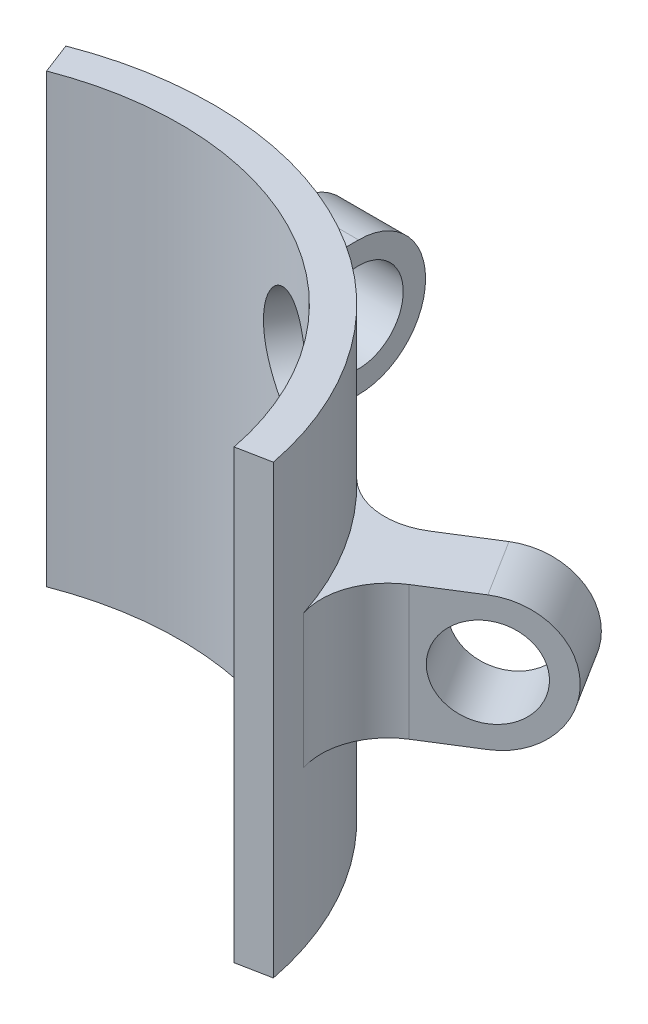
from build123d import *
from build123d.topology import SkipClean

# Parameters (mm, degrees)
SKETCH2_R               = 15.5
SKETCH2_R_2             = 14
BOSS_EXTRUDE1_DEPTH     = 20
SKETCH3_OUTSIDE_W       = 42.638
SKETCH3_OUTSIDE_H       = 42.638
CUT_EXTRUDE1_DEPTH      = 30.67322025
SKETCH6_R               = 2
BOSS_EXTRUDE2_DEPTH     = 1.5
CUT_EXTRUDE4_DEPTH      = 38.158292902
CUT_EXTRUDE4_DEPTH_BACK = 10
SKETCH9_R               = 2.5
CUT_EXTRUDE5_DEPTH      = 10
FILLET1_R               = 3


with BuildPart() as part:
    # Sketch2 → Boss-Extrude1 (new body)
    with BuildSketch(Plane(origin=(0, 0, 0), x_dir=(1, 0, 0), z_dir=(0, 1, 0))):
        Circle(SKETCH2_R)
        Circle(SKETCH2_R_2, mode=Mode.SUBTRACT)
    boss_extrude1 = extrude(amount=BOSS_EXTRUDE1_DEPTH)

    # Sketch3 outside → Cut-Extrude1 (cut, through all)
    with BuildSketch(Plane(origin=(0, 20, 0), x_dir=(1, 0, 0), z_dir=(0, 1, 0))):
        Rectangle(SKETCH3_OUTSIDE_W, SKETCH3_OUTSIDE_H)
        with BuildLine():
            Line((0, 0), (7.5, 13.564659966))
            ThreePointArc((7.5, 13.564659966), (0, 15.5), (-7.5, 13.564659966))
            Line((-7.5, 13.564659966), (0, 0))
        make_face(mode=Mode.SUBTRACT)
    extrude(amount=-CUT_EXTRUDE1_DEPTH, mode=Mode.SUBTRACT)

    # Sketch6 → Boss-Extrude2 (add, symmetric)
    with BuildSketch(Plane(origin=(0, 7.5, 0), x_dir=(0, 1, 0), z_dir=(-1, 0, 0))):
        with BuildLine():
            Line((-0.5, 20.5), (-0.5, 15.25))
            Line((-0.5, 15.25), (5.5, 15.25))
            Line((5.5, 15.25), (5.5, 20.5))
            ThreePointArc((5.5, 20.5), (2.5, 23.5), (-0.5, 20.5))
        make_face()
        with Locations((2.5, 20.5)):
            Circle(SKETCH6_R, mode=Mode.SUBTRACT)
    boss_extrude2 = extrude(amount=BOSS_EXTRUDE2_DEPTH, both=True)

    # Mirror2: Boss-Extrude1, Boss-Extrude2 across plane
    with SkipClean():  # the faces are left unmerged after this step: merging them gives an invalid solid
        add(boss_extrude1.mirror(Plane(origin=(0, 0, 0), x_dir=(-0.4838709677419353, 0, 0.8751393526613251), z_dir=(0.8751393526613249, 0, 0.48387096774193533))))
        add(boss_extrude2.mirror(Plane(origin=(0, 0, 0), x_dir=(-0.4838709677419353, 0, 0.8751393526613251), z_dir=(0.8751393526613249, 0, 0.48387096774193533))))

    # Sketch8 → Cut-Extrude4 (cut, two sides: drawn at the far end of the back side and taken through both)
    with SkipClean():  # the faces are left unmerged after this step: merging them gives an invalid solid
        with BuildSketch(Plane(origin=(0, 0, 0), x_dir=(1, 0, 0), z_dir=(0, 1, 0)).offset(-CUT_EXTRUDE4_DEPTH_BACK)):
            with BuildLine():
                Line((-5.570225317, 14.464528679), (0, 0))
                Line((0, 0), (15.212039463, 2.973862033))
                ThreePointArc((15.212039463, 2.973862033), (-7.5, -13.564659966), (-5.570225317, 14.464528679))
            make_face()
        extrude(amount=CUT_EXTRUDE4_DEPTH + CUT_EXTRUDE4_DEPTH_BACK, mode=Mode.SUBTRACT)

    # Sketch9 → Cut-Extrude5 (cut)
    with SkipClean():  # the faces are left unmerged after this step: merging them gives an invalid solid
        with BuildSketch(Plane(origin=(4.354367679, 0, -7.875402257), x_dir=(-0.875139352661325, 0, -0.4838709677419354), z_dir=(0.4838709677419354, 0, -0.875139352661325))):
            with Locations((0, 15)):
                Circle(SKETCH9_R)
            with Locations((0, 5)):
                Circle(SKETCH9_R)
        extrude(amount=CUT_EXTRUDE5_DEPTH, mode=Mode.SUBTRACT)

    # Fillet1
    fillet1_edges = [part.edges().sort_by_distance(p)[0] for p in [
        (13.863083148, 10, -6.932887251),
        (-1.5, 10, -15.427248621),
        (1.5, 10, -15.427248621),
        (12.267869828, 10, -9.473614404),
    ]]
    fillet(fillet1_edges, radius=FILLET1_R)


solid = part.part
